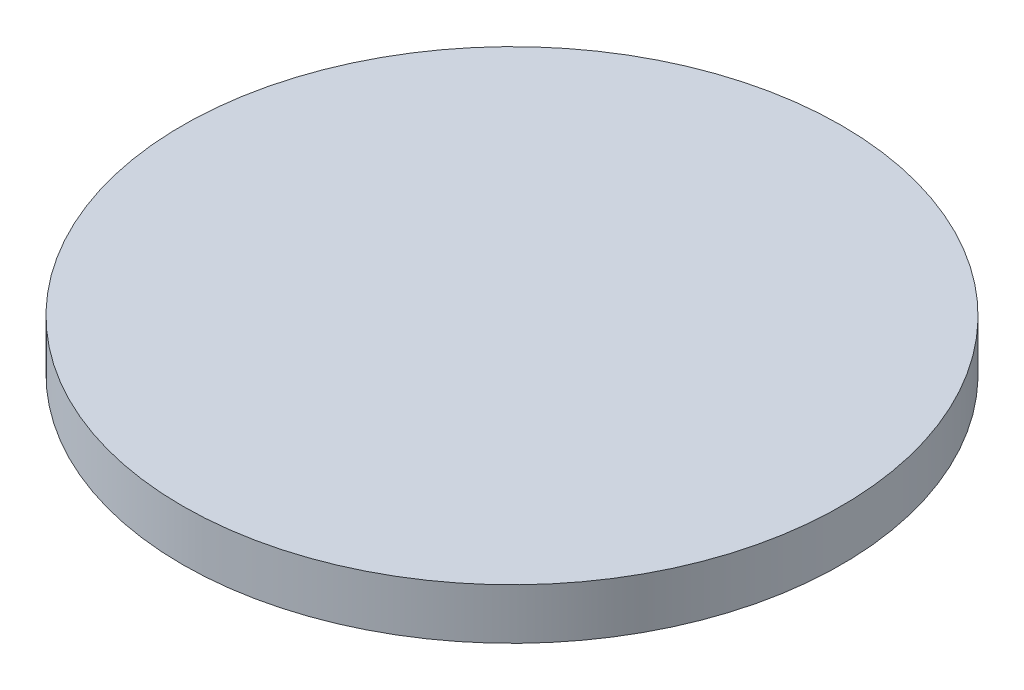
from build123d import *

# Parameters (mm, degrees)
SKETCH1_R           = 82.5
BOSS_EXTRUDE1_DEPTH = 12.7


with BuildPart() as part:
    # Sketch1 → Boss-Extrude1 (new body)
    with BuildSketch(Plane(origin=(0, 0, 0), x_dir=(1, 0, 0), z_dir=(0, 1, 0))):
        Circle(SKETCH1_R)
    extrude(amount=BOSS_EXTRUDE1_DEPTH)


solid = part.part
